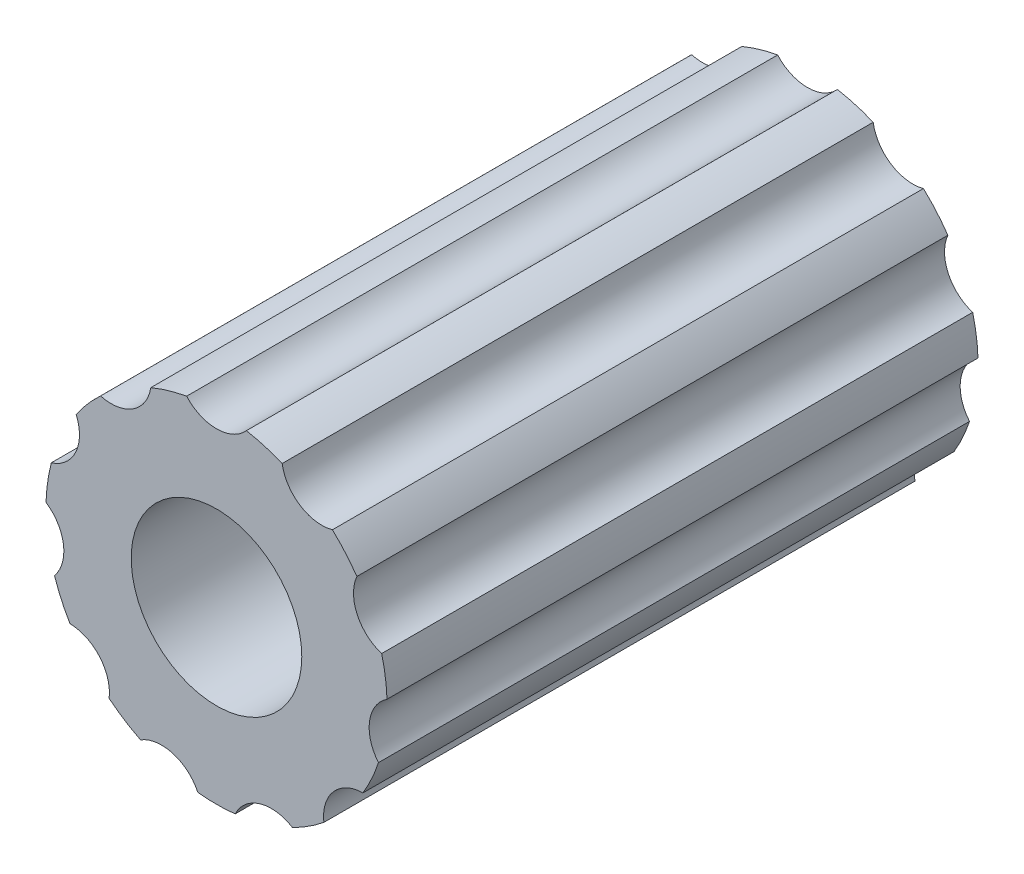
from build123d import *

# Parameters (mm, degrees)
SKETCH1_R           = 6.35
BOSS_EXTRUDE1_DEPTH = 22
CUT_EXTRUDE1_DEPTH  = 23
CIRPATTERN1_COUNT   = 11
SKETCH3_R           = 3.175
CUT_EXTRUDE2_DEPTH  = 19
SKETCH4_R           = 0.9525
CUT_EXTRUDE3_DEPTH  = 4


with BuildPart() as part:
    # Sketch1 → Boss-Extrude1 (new body)
    with BuildSketch(Plane.XY):
        Circle(SKETCH1_R)
    extrude(amount=BOSS_EXTRUDE1_DEPTH)

    # Sketch2 → Cut-Extrude1 (cut, through all)
    with BuildSketch(Plane.XY.offset(22)):
        with BuildLine():
            ThreePointArc((-1.111662599, 6.251936201), (0, 5.75547169), (1.111662599, 6.251936201))
            ThreePointArc((1.111662599, 6.251936201), (0, 6.35), (-1.111662599, 6.251936201))
        make_face()
    cut_extrude1 = extrude(amount=-CUT_EXTRUDE1_DEPTH, mode=Mode.SUBTRACT)

    # CirPattern1: Cut-Extrude1 ×11 about axis
    cirpattern1_axis = Axis((0, 0, 0), (0, 0, 1))
    for i in range(1, CIRPATTERN1_COUNT):
        add(cut_extrude1.rotate(cirpattern1_axis, i * 360 / CIRPATTERN1_COUNT), mode=Mode.SUBTRACT)

    # Sketch3 → Cut-Extrude2 (cut)
    with BuildSketch(Plane.XY.offset(22)):
        Circle(SKETCH3_R)
    extrude(amount=-CUT_EXTRUDE2_DEPTH, mode=Mode.SUBTRACT)

    # Sketch4 → Cut-Extrude3 (cut, through all)
    with BuildSketch(Plane.XY.offset(3)):
        Circle(SKETCH4_R)
    extrude(amount=-CUT_EXTRUDE3_DEPTH, mode=Mode.SUBTRACT)


solid = part.part
